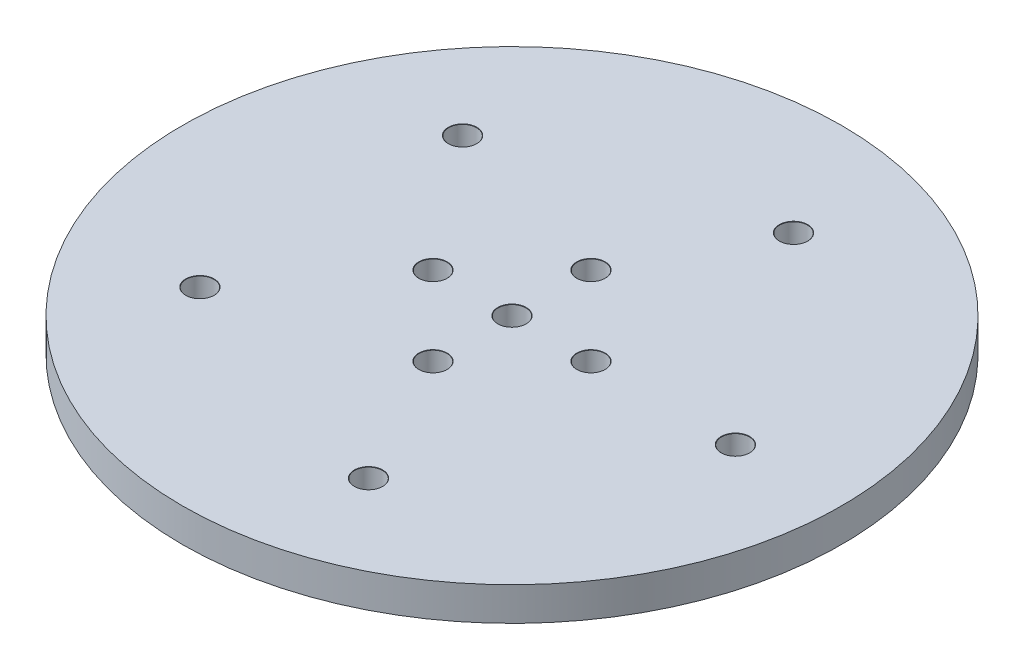
from build123d import *

# Parameters (mm, degrees)
SKETCH_1_R                   = 29.5
EXTRUDE_1_DEPTH              = 3
HOLE_WIZARD_M3_1_D           = 2.5
HOLE_WIZARD_M3_1_CSINK_D     = 2.55
HOLE_WIZARD_M3_1_CSINK_ANGLE = 90
HOLE_WIZARD_M3_2_D           = 2.5
HOLE_WIZARD_M3_2_CSINK_D     = 2.55
HOLE_WIZARD_M3_2_CSINK_ANGLE = 90


with BuildPart() as part:
    # 草图1 → 凸台-拉伸1 (new body)
    with BuildSketch(Plane(origin=(0, 0, 0), x_dir=(1, 0, 0), z_dir=(0, 1, 0))):
        Circle(SKETCH_1_R)
    extrude(amount=EXTRUDE_1_DEPTH)

    # M3 螺纹孔的螺纹孔钻头1 (through all)
    with Locations(Plane(origin=(0, 3, 0), x_dir=(1, 0, 0), z_dir=(0, 1, 0))):
        with Locations((6.180339887, 19.021130326), (20, 0), (6.180339887, -19.021130326), (-16.180339887, -11.755705046), (-16.180339887, 11.755705046)):
            CounterSinkHole(HOLE_WIZARD_M3_1_D / 2, HOLE_WIZARD_M3_1_CSINK_D / 2, counter_sink_angle=HOLE_WIZARD_M3_1_CSINK_ANGLE)

    # M3 螺纹孔的螺纹孔钻头2 (through all)
    with Locations(Plane(origin=(0, 3, 0), x_dir=(1, 0, 0), z_dir=(0, 1, 0))):
        with Locations((0, 0), (7.071067812, 0), (0, -7.071067812), (-7.071067812, 0), (0, 7.071067812)):
            CounterSinkHole(HOLE_WIZARD_M3_2_D / 2, HOLE_WIZARD_M3_2_CSINK_D / 2, counter_sink_angle=HOLE_WIZARD_M3_2_CSINK_ANGLE)


solid = part.part
